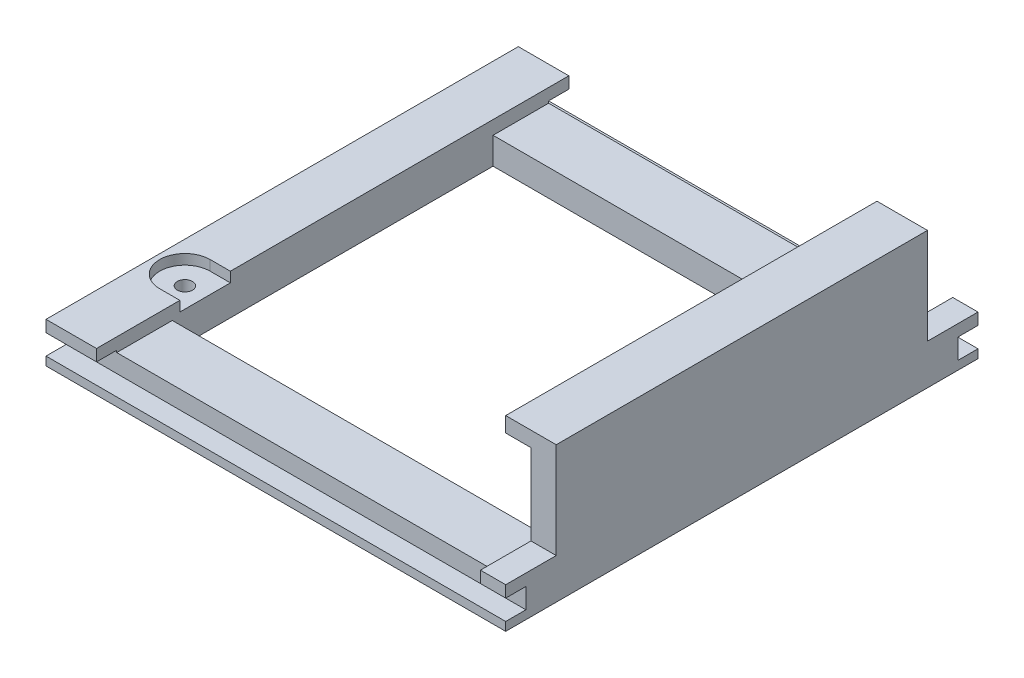
from build123d import *

# Parameters (mm, degrees)
ESQUISSE1_W             = 91
ESQUISSE1_H             = 73.5
ESQUISSE1_R             = 1.5
ESQUISSE1_W_2           = 76
ESQUISSE1_H_2           = 63.5
BOSS_EXTRU_1_DEPTH      = 8
ENL_V_MAT_EXTRU_1_DEPTH = 2
ESQUISSE3_W             = 76
ESQUISSE3_H             = 5
ENL_V_MAT_EXTRU_2_DEPTH = 2.7
BOSS_EXTRU_2_DEPTH      = 73.5
ESQUISSE5_W             = 91
ESQUISSE5_H             = 10
BOSS_EXTRU_3_DEPTH      = 5.3
ESQUISSE6_W             = 5
ESQUISSE6_H             = 10
ESQUISSE6_W_2           = 10
BOSS_EXTRU_4_DEPTH      = 2.7
ESQUISSE7_W             = 4
ESQUISSE7_H             = 4
ENL_V_MAT_EXTRU_3_DEPTH = 92


with BuildPart() as part:
    # Esquisse1 → Boss.-Extru.1 (new body)
    with BuildSketch(Plane(origin=(0, 0, 0), x_dir=(1, 0, 0), z_dir=(0, 1, 0))):
        with Locations((-2.5, 0)):
            Rectangle(ESQUISSE1_W, ESQUISSE1_H)
        with Locations((-42, -25.25)):
            Circle(ESQUISSE1_R, mode=Mode.SUBTRACT)
        Rectangle(ESQUISSE1_W_2, ESQUISSE1_H_2, mode=Mode.SUBTRACT)
    extrude(amount=BOSS_EXTRU_1_DEPTH)

    # Esquisse2 → Enlèv. mat.-Extru.1 (cut)
    with BuildSketch(Plane(origin=(0, 8, 0), x_dir=(1, 0, 0), z_dir=(0, 1, 0))):
        with BuildLine():
            Line((-42, -30.25), (-38, -30.25))
            Line((-38, -30.25), (-38, -20.25))
            Line((-38, -20.25), (-42, -20.25))
            ThreePointArc((-42, -20.25), (-47, -25.25), (-42, -30.25))
        make_face()
    extrude(amount=-ENL_V_MAT_EXTRU_1_DEPTH, mode=Mode.SUBTRACT)

    # Esquisse3 → Enlèv. mat.-Extru.2 (cut)
    with BuildSketch(Plane(origin=(0, 8, 0), x_dir=(1, 0, 0), z_dir=(0, 1, 0))):
        with Locations((0, -34.25)):
            Rectangle(ESQUISSE3_W, ESQUISSE3_H)
        with Locations((0, 34.25)):
            Rectangle(ESQUISSE3_W, ESQUISSE3_H)
    extrude(amount=-ENL_V_MAT_EXTRU_2_DEPTH, mode=Mode.SUBTRACT)

    # Esquisse4 → Boss.-Extru.2 (add)
    with BuildSketch(Plane(origin=(0, 0, -36.75), x_dir=(-1, 0, 0), z_dir=(0, 0, -1))):
        Polygon((-43, 8), (-38, 8), (-38, 24), (-33, 24), (-33, 27), (-38.815944916, 27), (-43, 27), align=None)
    extrude(amount=-BOSS_EXTRU_2_DEPTH)

    # Esquisse5 → Boss.-Extru.3 (add)
    with BuildSketch(Plane.XZ):
        with Locations((-2.5, -41.75)):
            Rectangle(ESQUISSE5_W, ESQUISSE5_H)
        with Locations((-2.5, 41.75)):
            Rectangle(ESQUISSE5_W, ESQUISSE5_H)
    extrude(amount=-BOSS_EXTRU_3_DEPTH)

    # Esquisse6 → Boss.-Extru.4 (add)
    with BuildSketch(Plane(origin=(0, 5.3, 0), x_dir=(1, 0, 0), z_dir=(0, 1, 0))):
        with Locations((40.5, 41.75)):
            Rectangle(ESQUISSE6_W, ESQUISSE6_H)
        with Locations((40.5, -41.75)):
            Rectangle(ESQUISSE6_W, ESQUISSE6_H)
        with Locations((-43, 41.75)):
            Rectangle(ESQUISSE6_W_2, ESQUISSE6_H)
        with Locations((-43, -41.75)):
            Rectangle(ESQUISSE6_W_2, ESQUISSE6_H)
    extrude(amount=BOSS_EXTRU_4_DEPTH)

    # Esquisse7 → Enlèv. mat.-Extru.3 (cut, through all)
    with BuildSketch(Plane.ZY.offset(48)):
        with Locations((-44.75, 3.7)):
            Rectangle(ESQUISSE7_W, ESQUISSE7_H)
        with Locations((44.75, 3.7)):
            Rectangle(ESQUISSE7_W, ESQUISSE7_H)
    extrude(amount=-ENL_V_MAT_EXTRU_3_DEPTH, mode=Mode.SUBTRACT)


solid = part.part
